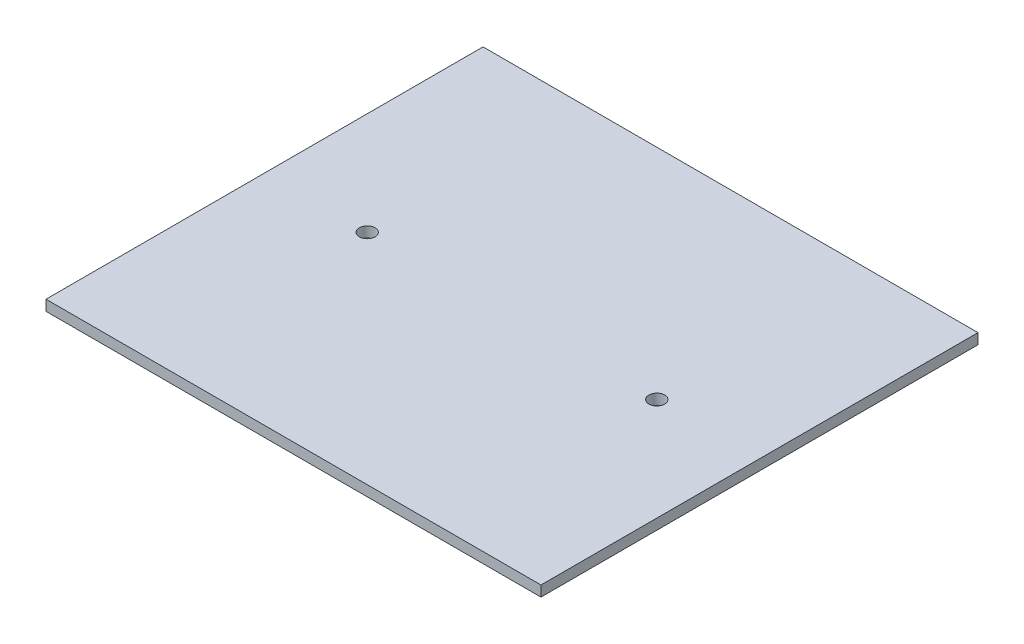
from build123d import *

# Parameters (mm, degrees)
SKETCH1_W           = 94
SKETCH1_H           = 83
BOSS_EXTRUDE1_DEPTH = 2
SKETCH2_R           = 1.5
CUT_EXTRUDE1_DEPTH  = 3


with BuildPart() as part:
    # Sketch1 → Boss-Extrude1 (new body)
    with BuildSketch(Plane(origin=(0, 0, 0), x_dir=(1, 0, 0), z_dir=(0, 1, 0))):
        Rectangle(SKETCH1_W, SKETCH1_H)
    extrude(amount=BOSS_EXTRUDE1_DEPTH)

    # Sketch2 → Cut-Extrude1 (cut, through all)
    with BuildSketch(Plane(origin=(0, 2, 0), x_dir=(1, 0, 0), z_dir=(0, 1, 0))):
        with Locations((27.5, 0)):
            Circle(SKETCH2_R)
        with Locations((-27.5, 0)):
            Circle(SKETCH2_R)
    extrude(amount=-CUT_EXTRUDE1_DEPTH, mode=Mode.SUBTRACT)


solid = part.part
